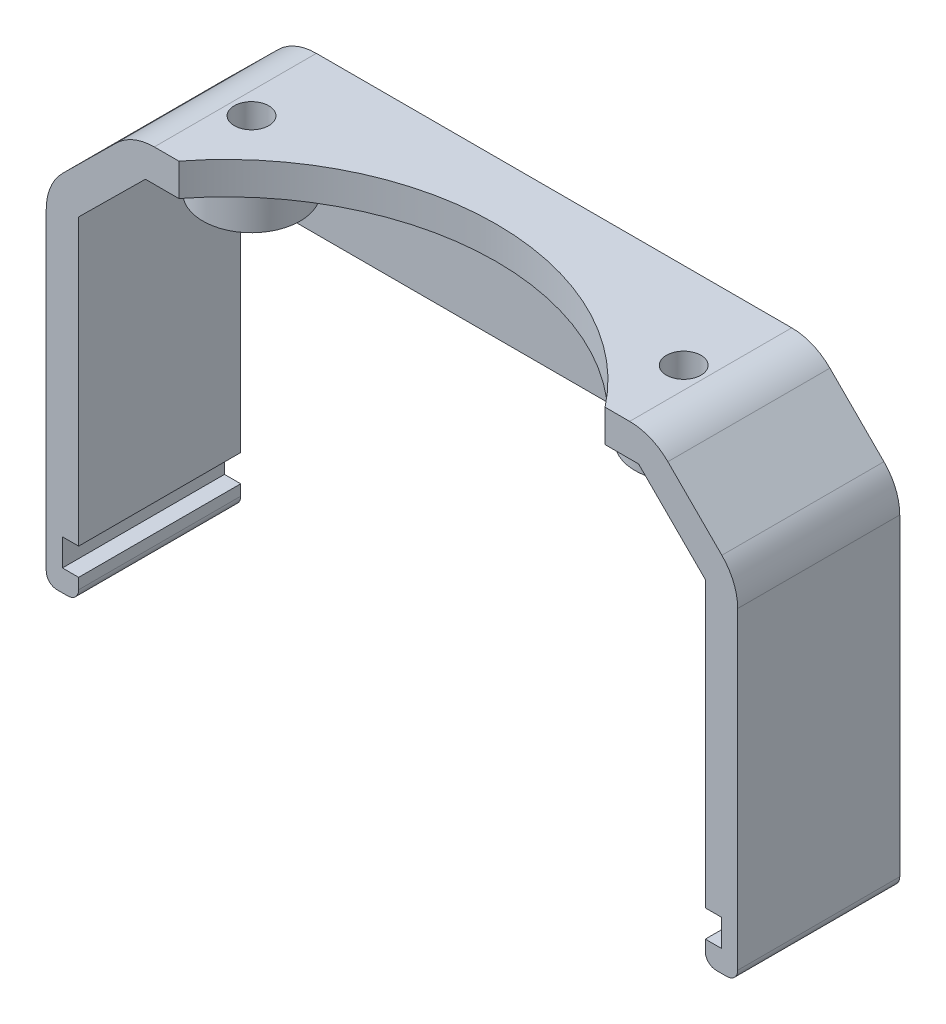
from build123d import *

# Parameters (mm, degrees)
SALIENTE_EXTRUIR2_DEPTH = 15
SALIENTE_EXTRUIR3_DEPTH = 1.5
CROQUIS2_R              = 1.6
CORTAR_EXTRUIR1_DEPTH   = 10
CROQUIS4_R              = 4.5
SALIENTE_EXTRUIR4_DEPTH = 3.2
CORTAR_EXTRUIR2_REACH   = 42


with BuildPart() as part:
    # Croquis1 → Saliente-Extruir2 (new body)
    with BuildSketch(Plane.XY):
        with BuildLine():
            Line((51.828427125, 37), (6.178295218, 37))
            Line((6.178295218, 37), (0, 30.892284874))
            Line((0, 30.892284874), (0, 4.5))
            Line((0, 4.5), (-1.5, 4.5))
            Line((-1.5, 4.5), (-1.5, 2))
            Line((-1.5, 2), (0, 2))
            Line((0, 2), (0, 1))
            ThreePointArc((0, 1), (-0.292893219, 0.292893219), (-1, 0))
            Line((-1, 0), (-2, 0))
            ThreePointArc((-2, 0), (-2.707106781, 0.292893219), (-3, 1))
            Line((-3, 1), (-3, 30))
            ThreePointArc((-3, 30), (-2.603319545, 31.979386186), (-1.474544268, 33.65306221))
            Line((-1.474544268, 33.65306221), (3.484834866, 38.555786))
            ThreePointArc((3.484834866, 38.555786), (5.099859216, 39.624874593), (7, 40))
            Line((7, 40), (51, 40))
            ThreePointArc((51, 40), (52.913417162, 39.619397663), (54.535533906, 38.535533906))
            Line((54.535533906, 38.535533906), (59.535533906, 33.535533906))
            ThreePointArc((59.535533906, 33.535533906), (60.619397663, 31.913417162), (61, 30))
            Line((61, 30), (61, 1))
            ThreePointArc((61, 1), (60.707106781, 0.292893219), (60, 0))
            Line((60, 0), (59, 0))
            ThreePointArc((59, 0), (58.292893219, 0.292893219), (58, 1))
            Line((58, 1), (58, 2))
            Line((58, 2), (59.5, 2))
            Line((59.5, 2), (59.5, 4.5))
            Line((59.5, 4.5), (58, 4.5))
            Line((58, 4.5), (58, 30.828427125))
            Line((58, 30.828427125), (51.828427125, 37))
        make_face()
    extrude(amount=SALIENTE_EXTRUIR2_DEPTH)

    # Croquis3 → Saliente-Extruir3 (add)
    with BuildSketch(Plane.XY):
        Polygon((0, 27), (58, 27), (58, 30.828427125), (51.828427125, 37), (6.178295218, 37), (0, 30.892284874), align=None)
    extrude(amount=SALIENTE_EXTRUIR3_DEPTH)

    # Croquis2 → Cortar-Extruir1 (cut)
    with BuildSketch(Plane(origin=(0, 40, 0), x_dir=(1, 0, 0), z_dir=(0, 1, 0))):
        with Locations((9, -8)):
            Circle(CROQUIS2_R)
        with Locations((49, -8)):
            Circle(CROQUIS2_R)
    extrude(amount=-CORTAR_EXTRUIR1_DEPTH, mode=Mode.SUBTRACT)

    # Croquis4 → Saliente-Extruir4 (add)
    with BuildSketch(Plane.XZ.offset(-37)):
        with Locations((49, 8)):
            Circle(CROQUIS4_R)
        Polygon((52.05, 8), (50.525, 10.641377482), (47.475, 10.641377482), (45.95, 8), (47.475, 5.358622518), (50.525, 5.358622518), align=None, mode=Mode.SUBTRACT)
        with Locations((9, 8)):
            Circle(CROQUIS4_R)
        Polygon((10.525, 10.641377482), (7.475, 10.641377482), (5.95, 8), (7.475, 5.358622518), (10.525, 5.358622518), (12.05, 8), align=None, mode=Mode.SUBTRACT)
    extrude(amount=SALIENTE_EXTRUIR4_DEPTH)

    # Croquis5 → Cortar-Extruir2 (cut, up to next)
    with BuildSketch(Plane(origin=(0, 40, 0), x_dir=(1, 0, 0), z_dir=(0, 1, 0)), mode=Mode.PRIVATE) as cortar_extruir2_sk1:
        with BuildLine():
            Line((9.275661815, -15), (48.724338185, -15))
            ThreePointArc((48.724338185, -15), (29, -5.360679775), (9.275661815, -15))
        make_face()
    cortar_extruir2_tool1 = extrude(cortar_extruir2_sk1.sketch, amount=-CORTAR_EXTRUIR2_REACH, mode=Mode.PRIVATE) & part.part
    add(cortar_extruir2_tool1.solids().sort_by_distance((29, 40, 11.072485))[0], mode=Mode.SUBTRACT)


solid = part.part
